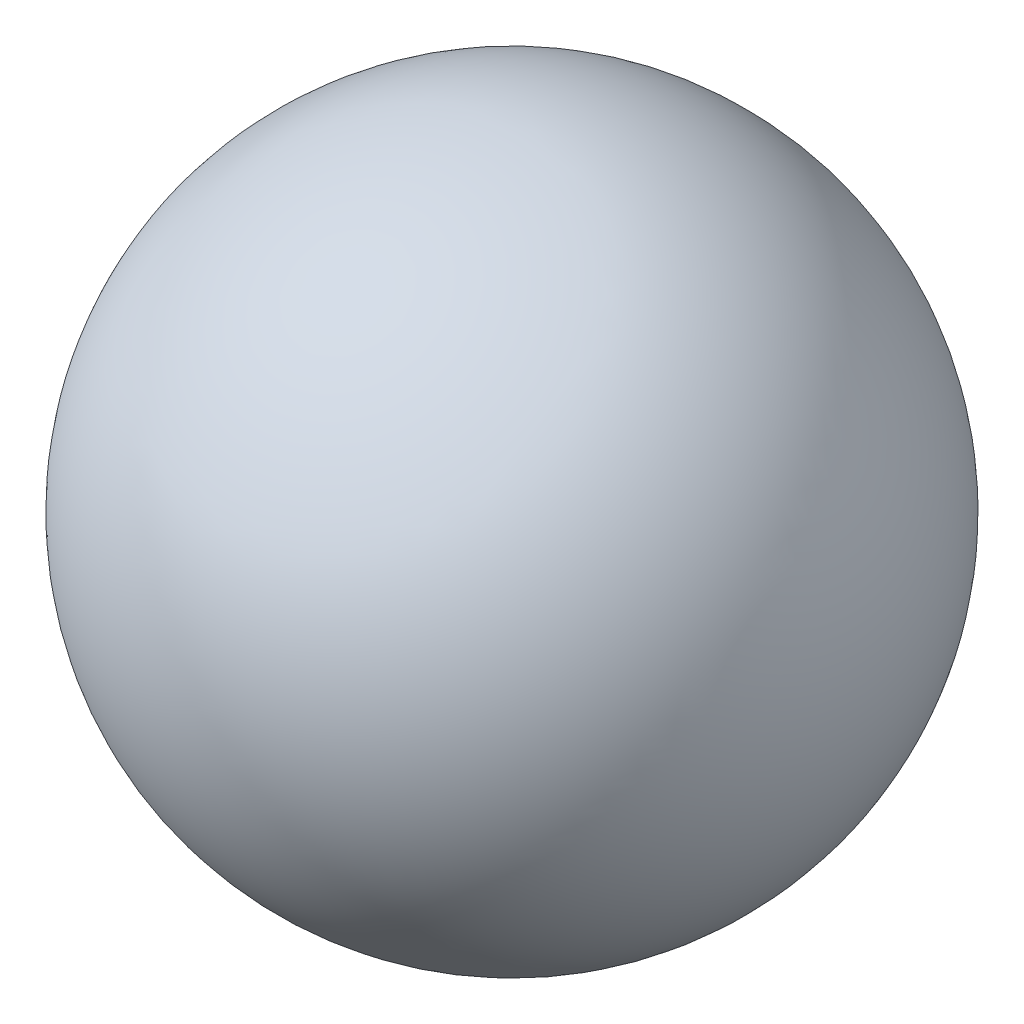
from build123d import *


with BuildPart() as part:
    # Sketch1 → Revolve1 (revolve)
    with BuildSketch(Plane.XY):
        with BuildLine():
            Line((-4.233333333, 0), (4.233333333, 0))
            ThreePointArc((4.233333333, 0), (0, 4.233333333), (-4.233333333, 0))
        make_face()
    revolve(axis=Axis((-15.275591218, 0, 0), (1, 0, 0)))


solid = part.part
